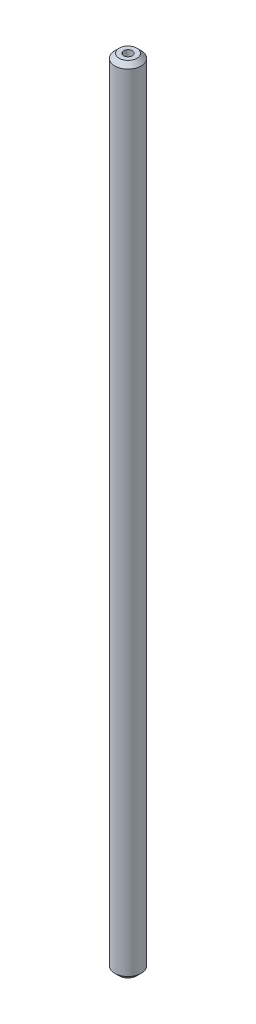
from build123d import *

# Parameters (mm, degrees)
SKETCH1_R           = 1.5
SKETCH1_R_2         = 0.5
BOSS_EXTRUDE1_DEPTH = 90
CHAMFER1_SIZE       = 0.5


with BuildPart() as part:
    # Sketch1 → Boss-Extrude1 (new body)
    with BuildSketch(Plane(origin=(0, 0, 0), x_dir=(1, 0, 0), z_dir=(0, 1, 0))):
        Circle(SKETCH1_R)
        Circle(SKETCH1_R_2, mode=Mode.SUBTRACT)
    extrude(amount=BOSS_EXTRUDE1_DEPTH)

    # Chamfer1
    chamfer1_edges = [part.edges().sort_by_distance(p)[0] for p in [
        (-1.5, 0, 0),
        (-1.5, 90, 0),
    ]]
    chamfer(chamfer1_edges, length=CHAMFER1_SIZE)


solid = part.part
